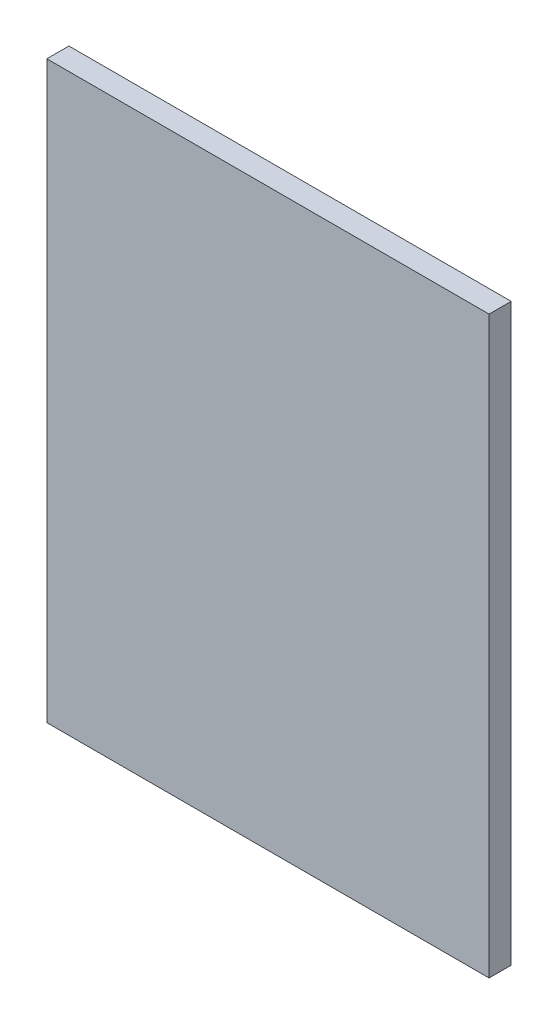
from build123d import *

# Parameters (mm, degrees)
SKETCH1_W           = 100
SKETCH1_H           = 130
BOSS_EXTRUDE1_DEPTH = 5


with BuildPart() as part:
    # Sketch1 → Boss-Extrude1 (new body)
    with BuildSketch(Plane.XY):
        Rectangle(SKETCH1_W, SKETCH1_H)
    extrude(amount=BOSS_EXTRUDE1_DEPTH)


solid = part.part
